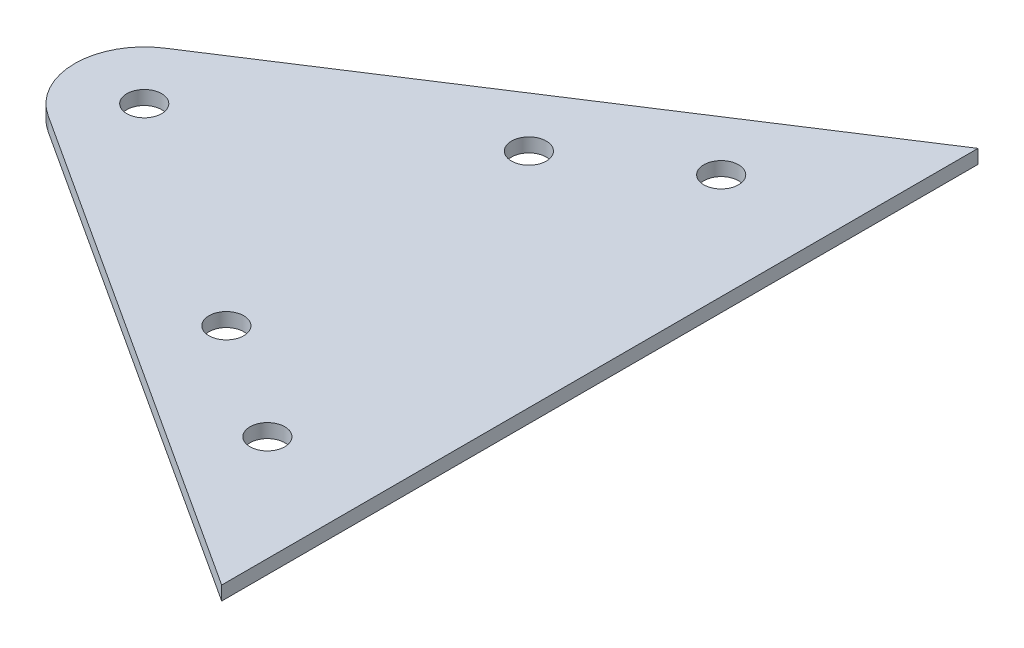
from build123d import *

# Parameters (mm, degrees)
SKETCH2_R           = 2.5
BOSS_EXTRUDE2_DEPTH = 2


with BuildPart() as part:
    # Sketch2 → Boss-Extrude2 (new body)
    with BuildSketch(Plane(origin=(0, 0, 0), x_dir=(1, 0, 0), z_dir=(0, 1, 0))):
        with BuildLine():
            Line((14.393173744, 58.640634372), (-56.574951574, 12.641394771))
            ThreePointArc((-56.574951574, 12.641394771), (-61.135882078, 4.249939413), (-56.574951574, -4.141515944))
            Line((-56.574951574, -4.141515944), (14.393173744, -50.140755545))
            Line((14.393173744, -50.140755545), (14.393173744, 58.640634372))
        make_face()
        with Locations((-51.135882078, 4.249939413)):
            Circle(SKETCH2_R, mode=Mode.SUBTRACT)
        with Locations((-17.570060648, 26.006217397)):
            Circle(SKETCH2_R, mode=Mode.SUBTRACT)
        with Locations((-0.787149932, 36.884356389)):
            Circle(SKETCH2_R, mode=Mode.SUBTRACT)
        with Locations((-17.570060648, -17.50633857)):
            Circle(SKETCH2_R, mode=Mode.SUBTRACT)
        with Locations((-0.787149932, -28.384477562)):
            Circle(SKETCH2_R, mode=Mode.SUBTRACT)
    extrude(amount=BOSS_EXTRUDE2_DEPTH)


solid = part.part
